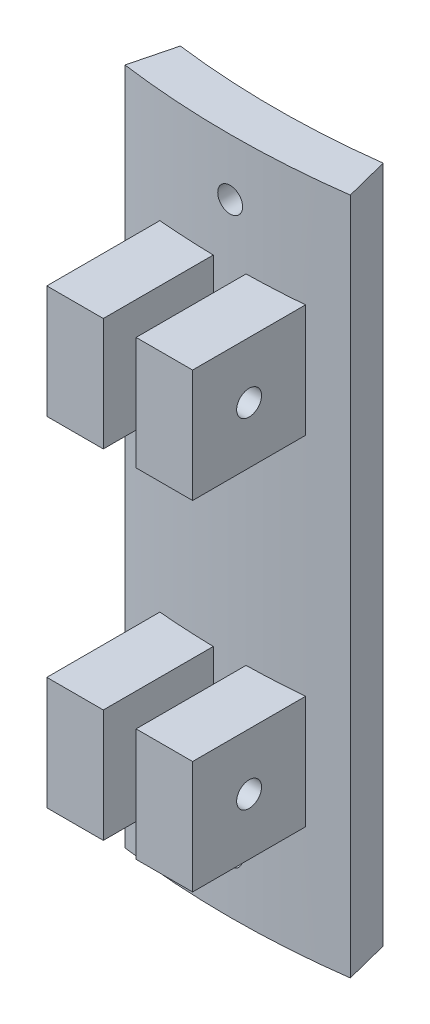
from build123d import *

# Parameters (mm, degrees)
BOSS_EXTRUDE1_DEPTH     = 76.2
SKETCH3_R               = 1.397
CUT_EXTRUDE2_DEPTH      = 25.4
CUT_EXTRUDE4_REACH      = 81.348
CUT_EXTRUDE4_END_RADIUS = 94.615
SKETCH6_W               = 16.383
SKETCH6_H               = 25.4
SKETCH6_H_2             = 12.7
SKETCH7_R               = 1.397
CUT_EXTRUDE5_DEPTH      = 50.8


with BuildPart() as part:
    # Sketch1 → Boss-Extrude1 (new body)
    with BuildSketch(Plane(origin=(0, 0, 0), x_dir=(1, 0, 0), z_dir=(0, 1, 0))):
        with BuildLine():
            Line((-8.255, -94.254194602), (-8.255, -106.954194602))
            Line((-8.255, -106.954194602), (-1.905, -106.954194602))
            Line((-1.905, -106.954194602), (-1.905, -94.595820204))
            ThreePointArc((-1.905, -94.595820204), (-0.063512031, -94.614978683), (1.778, -94.598292485))
            Line((1.778, -94.598292485), (1.778, -106.954194602))
            Line((1.778, -106.954194602), (8.128, -106.954194602))
            Line((8.128, -106.954194602), (8.128, -94.265231348))
            ThreePointArc((8.128, -94.265231348), (10.397970458, -94.041907867), (12.661897921, -93.763929984))
            Line((12.661897921, -93.763929984), (11.398979566, -88.806415815))
            ThreePointArc((11.398979566, -88.806415815), (0, -89.535), (-11.398979566, -88.806415815))
            Line((-11.398979566, -88.806415815), (-12.661897921, -93.763929984))
            ThreePointArc((-12.661897921, -93.763929984), (-10.461321356, -94.034881722), (-8.255, -94.254194602))
        make_face()
    extrude(amount=BOSS_EXTRUDE1_DEPTH)

    # Sketch3 → Cut-Extrude2 (cut)
    with BuildSketch(Plane.ZY.offset(8.255)):
        with Locations((100.604194602, 57.15)):
            Circle(SKETCH3_R)
        with Locations((100.604194602, 19.05)):
            Circle(SKETCH3_R)
    extrude(amount=-CUT_EXTRUDE2_DEPTH, mode=Mode.SUBTRACT)

    # Cut-Extrude4: up to this cylinder (the profile starts outside it)
    cut_extrude4_end = Plane(origin=(0, 38.1, 0), z_dir=(0, -1, 0)) * Cylinder(CUT_EXTRUDE4_END_RADIUS, 416.426, mode=Mode.PRIVATE)
    # Sketch6 → Cut-Extrude4 (cut, up to the surface)
    with BuildSketch(Plane.XY.offset(106.954194602), mode=Mode.PRIVATE) as cut_extrude4_sk1:
        with Locations((-0.0635, 38.1)):
            Rectangle(SKETCH6_W, SKETCH6_H)
    cut_extrude4_tool1 = extrude(cut_extrude4_sk1.sketch, amount=-CUT_EXTRUDE4_REACH, mode=Mode.PRIVATE) - cut_extrude4_end
    add(cut_extrude4_tool1.solids().sort_by_distance((-0.0635, 38.1, 106.954195))[0], mode=Mode.SUBTRACT)
    # Sketch6 → Cut-Extrude4 (cut, up to the surface)
    with BuildSketch(Plane.XY.offset(106.954194602), mode=Mode.PRIVATE) as cut_extrude4_sk2:
        with Locations((-0.0635, 69.85)):
            Rectangle(SKETCH6_W, SKETCH6_H_2)
    cut_extrude4_tool2 = extrude(cut_extrude4_sk2.sketch, amount=-CUT_EXTRUDE4_REACH, mode=Mode.PRIVATE) - cut_extrude4_end
    add(cut_extrude4_tool2.solids().sort_by_distance((-0.0635, 69.85, 106.954195))[0], mode=Mode.SUBTRACT)
    # Sketch6 → Cut-Extrude4 (cut, up to the surface)
    with BuildSketch(Plane.XY.offset(106.954194602), mode=Mode.PRIVATE) as cut_extrude4_sk3:
        with Locations((-0.0635, 6.35)):
            Rectangle(SKETCH6_W, SKETCH6_H_2)
    cut_extrude4_tool3 = extrude(cut_extrude4_sk3.sketch, amount=-CUT_EXTRUDE4_REACH, mode=Mode.PRIVATE) - cut_extrude4_end
    add(cut_extrude4_tool3.solids().sort_by_distance((-0.0635, 6.35, 106.954195))[0], mode=Mode.SUBTRACT)

    # Sketch7 → Cut-Extrude5 (cut)
    with BuildSketch(Plane.XY.offset(106.954194602)):
        with Locations((0, 69.85)):
            Circle(SKETCH7_R)
        with Locations((0, 6.35)):
            Circle(SKETCH7_R)
    extrude(amount=-CUT_EXTRUDE5_DEPTH, mode=Mode.SUBTRACT)


solid = part.part
